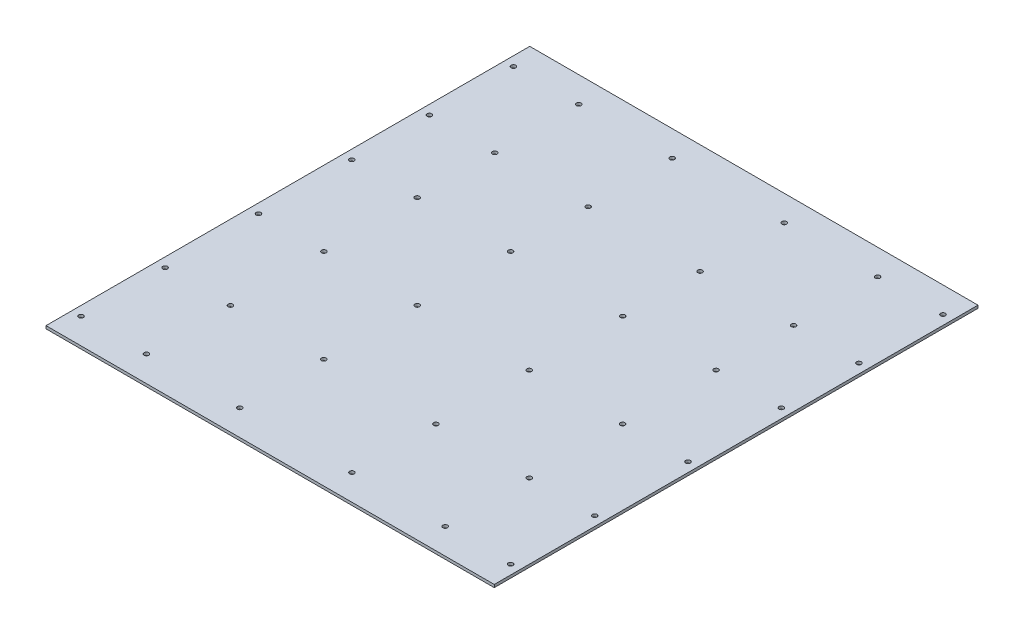
from build123d import *

# Parameters (mm, degrees)
CROQUIS1_W              = 480
CROQUIS1_H              = 518
SALIENTE_EXTRUIR1_DEPTH = 3
CROQUIS4_R              = 2.5
CORTAR_EXTRUIR2_DEPTH   = 3


with BuildPart() as part:
    # Croquis1 → Saliente-Extruir1 (new body)
    with BuildSketch(Plane(origin=(0, 0, 0), x_dir=(1, 0, 0), z_dir=(0, 1, 0))):
        Rectangle(CROQUIS1_W, CROQUIS1_H)
    extrude(amount=SALIENTE_EXTRUIR1_DEPTH)

    # Croquis4 → Cortar-Extruir2 (cut)
    with BuildSketch(Plane(origin=(0, 3, 0), x_dir=(1, 0, 0), z_dir=(0, 1, 0))):
        with Locations((-230, -231.5)):
            Circle(CROQUIS4_R)
        with Locations((-230, 231.5)):
            Circle(CROQUIS4_R)
        with Locations((-230, -141.5)):
            Circle(CROQUIS4_R)
        with Locations((-230, 141.5)):
            Circle(CROQUIS4_R)
        with Locations((-230, -41.5)):
            Circle(CROQUIS4_R)
        with Locations((-230, 58.5)):
            Circle(CROQUIS4_R)
        with Locations((-160, 231.5)):
            Circle(CROQUIS4_R)
        with Locations((-160, 141.5)):
            Circle(CROQUIS4_R)
        with Locations((-160, 58.5)):
            Circle(CROQUIS4_R)
        with Locations((-160, -41.5)):
            Circle(CROQUIS4_R)
        with Locations((-160, -141.5)):
            Circle(CROQUIS4_R)
        with Locations((-160, -231.5)):
            Circle(CROQUIS4_R)
        with Locations((160, -231.5)):
            Circle(CROQUIS4_R)
        with Locations((160, -141.5)):
            Circle(CROQUIS4_R)
        with Locations((160, -41.5)):
            Circle(CROQUIS4_R)
        with Locations((160, 58.5)):
            Circle(CROQUIS4_R)
        with Locations((160, 141.5)):
            Circle(CROQUIS4_R)
        with Locations((160, 231.5)):
            Circle(CROQUIS4_R)
        with Locations((230, -231.5)):
            Circle(CROQUIS4_R)
        with Locations((230, -141.5)):
            Circle(CROQUIS4_R)
        with Locations((230, -41.5)):
            Circle(CROQUIS4_R)
        with Locations((230, 58.5)):
            Circle(CROQUIS4_R)
        with Locations((230, 141.5)):
            Circle(CROQUIS4_R)
        with Locations((230, 231.5)):
            Circle(CROQUIS4_R)
        with Locations((-60, 231.5)):
            Circle(CROQUIS4_R)
        with Locations((-60, 141.5)):
            Circle(CROQUIS4_R)
        with Locations((-60, 58.5)):
            Circle(CROQUIS4_R)
        with Locations((-60, -41.5)):
            Circle(CROQUIS4_R)
        with Locations((-60, -141.5)):
            Circle(CROQUIS4_R)
        with Locations((-60, -231.5)):
            Circle(CROQUIS4_R)
        with Locations((60, -231.5)):
            Circle(CROQUIS4_R)
        with Locations((60, -141.5)):
            Circle(CROQUIS4_R)
        with Locations((60, -41.5)):
            Circle(CROQUIS4_R)
        with Locations((60, 58.5)):
            Circle(CROQUIS4_R)
        with Locations((60, 141.5)):
            Circle(CROQUIS4_R)
        with Locations((60, 231.5)):
            Circle(CROQUIS4_R)
    extrude(amount=-CORTAR_EXTRUIR2_DEPTH, mode=Mode.SUBTRACT)


solid = part.part
